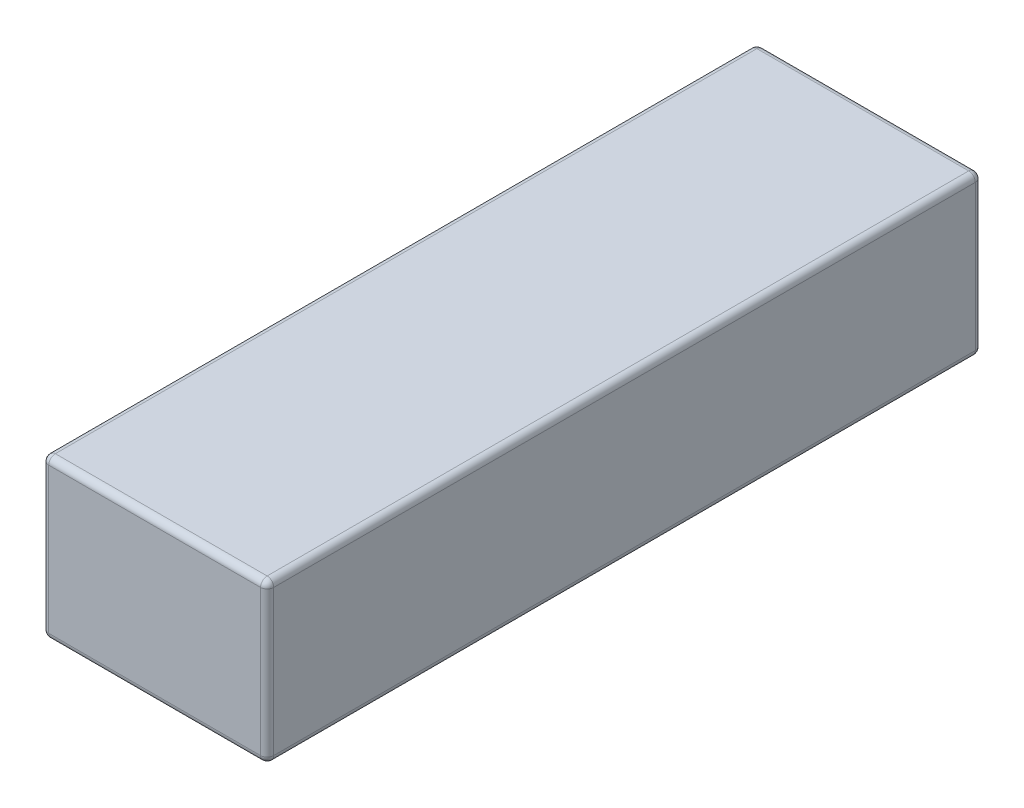
from build123d import *

# Parameters (mm, degrees)
SKETCH1_W           = 34
SKETCH1_H           = 24
BOSS_EXTRUDE1_DEPTH = 108
FILLET1_R           = 1


with BuildPart() as part:
    # Sketch1 → Boss-Extrude1 (new body)
    with BuildSketch(Plane.XY):
        Rectangle(SKETCH1_W, SKETCH1_H)
    extrude(amount=BOSS_EXTRUDE1_DEPTH)

    # Fillet1
    fillet1_edges = [part.edges().sort_by_distance(p)[0] for p in [
        (17, 0, 108),
        (0, 12, 108),
        (-17, 0, 108),
        (0, 12, 0),
        (17, 0, 0),
        (0, -12, 0),
        (-17, 0, 0),
        (0, -12, 108),
        (-17, 12, 54),
        (17, 12, 54),
        (17, -12, 54),
        (-17, -12, 54),
    ]]
    fillet(fillet1_edges, radius=FILLET1_R)


solid = part.part
